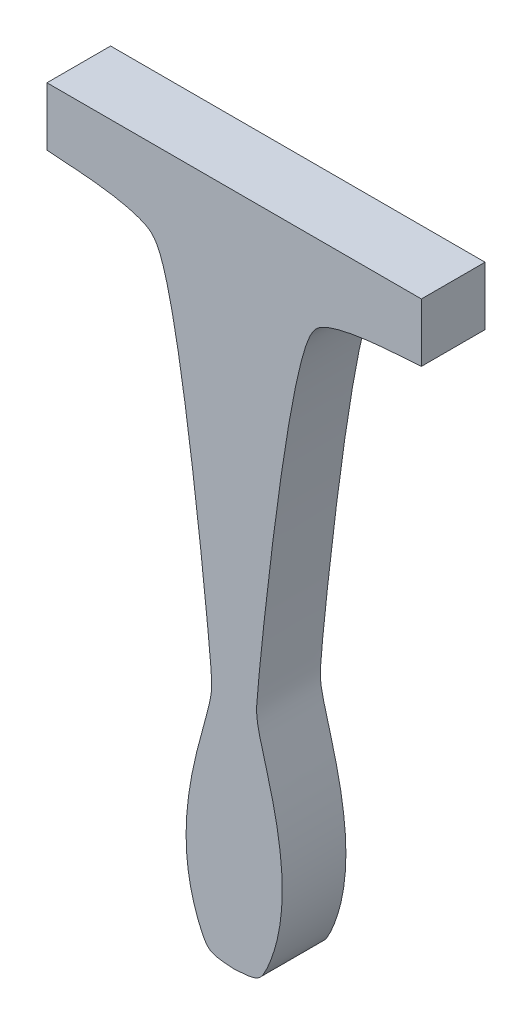
from build123d import *

# Parameters (mm, degrees)
BOSS_EXTRU_1_DEPTH = 8.5


with BuildPart() as part:
    # Esquisse1 → Boss.-Extru.1 (new body)
    with BuildSketch(Plane.XY):
        with BuildLine():
            Line((25, 24.622469849), (-25, 24.622469849))
            Line((-25, 24.622469849), (-25, 16.822469849))
            add(Edge.make_bspline(
                [(-25, 16.822469849), (-22.673975673, 16.579509698), (-13.8510419, 16.455818156), (-7.700002429, 11.875938279), (-3.130737324, -30.247059988), (-2.792789918, -37.237137101), (-8.924955183, -51.751667059), (-3.699846836, -65.01603726), (-2.698788395, -65.193021916), (0, -65.377530151)],
                knots=[0, 0, 0, 0, 0.256782562, 0.32028115, 0.600018686, 0.665715782, 0.911555016, 0.948056428, 1, 1, 1, 1], degree=3))
            add(Edge.make_bspline(
                [(25, 16.822469849), (22.673975673, 16.579509698), (13.8510419, 16.455818156), (7.700002429, 11.875938279), (3.130737324, -30.247059988), (2.792789918, -37.237137101), (8.924955183, -51.751667059), (3.699846836, -65.01603726), (2.698788395, -65.193021916), (0, -65.377530151)],
                knots=[0, 0, 0, 0, 0.256782562, 0.32028115, 0.600018686, 0.665715782, 0.911555016, 0.948056428, 1, 1, 1, 1], degree=3))
            Line((25, 16.822469849), (25, 24.622469849))
        make_face()
    extrude(amount=BOSS_EXTRU_1_DEPTH)


solid = part.part
